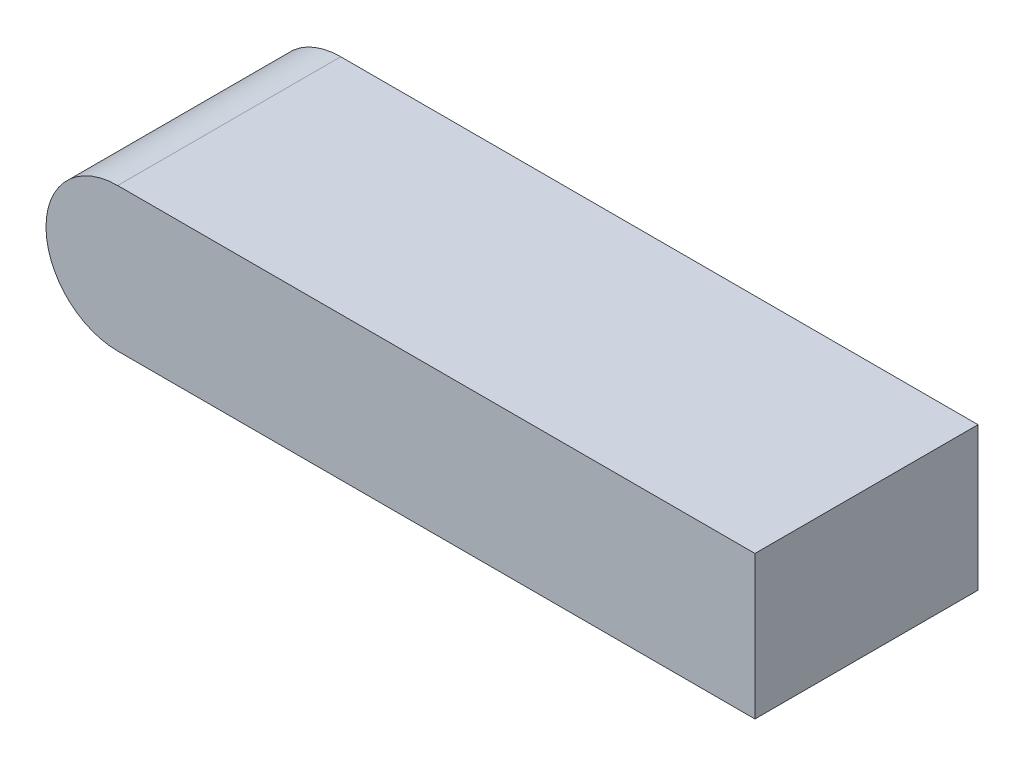
from build123d import *

# Parameters (mm, degrees)
SKETCH1_W           = 127
SKETCH1_H           = 44.45
BOSS_EXTRUDE1_DEPTH = 14.2875
BOSS_EXTRUDE2_DEPTH = 44.45


with BuildPart() as part:
    # Sketch1 → Boss-Extrude1 (new body, symmetric)
    with BuildSketch(Plane(origin=(0, 0, 0), x_dir=(1, 0, 0), z_dir=(0, 1, 0))):
        Rectangle(SKETCH1_W, SKETCH1_H)
    extrude(amount=BOSS_EXTRUDE1_DEPTH, both=True)

    # Sketch2 → Boss-Extrude2 (add)
    with BuildSketch(Plane(origin=(0, 0, -22.225), x_dir=(-1, 0, 0), z_dir=(0, 0, -1))):
        with BuildLine():
            Line((63.5, -14.2875), (63.5, 14.2875))
            ThreePointArc((63.5, 14.2875), (77.7875, 0), (63.5, -14.2875))
        make_face()
    extrude(amount=-BOSS_EXTRUDE2_DEPTH)


solid = part.part
